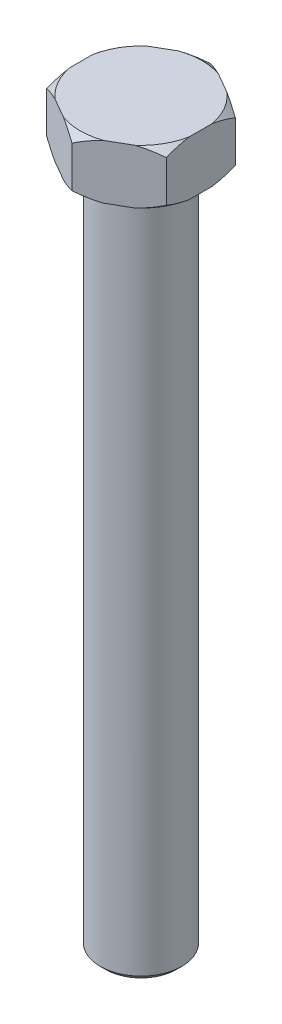
from build123d import *

# Parameters (mm, degrees)
BOSS_EXTRUDE1_DEPTH = 10
SKETCH2_R           = 7.5
BOSS_EXTRUDE2_DEPTH = 126
CHAMFER1_SIZE       = 1
SCALE1_SCALE        = 0.18
SCALE2_SCALE        = 1.04


with BuildPart() as part:
    # Sketch1 → Boss-Extrude1 (new body)
    with BuildSketch(Plane(origin=(0, 0, 0), x_dir=(1, 0, 0), z_dir=(0, 1, 0))):
        Polygon((0, 12.701705922), (-11, 6.350852961), (-11, -6.350852961), (0, -12.701705922), (11, -6.350852961), (11, 6.350852961), align=None)
    extrude(amount=BOSS_EXTRUDE1_DEPTH)

    # Sketch2 → Boss-Extrude2 (add)
    with BuildSketch(Plane.XZ):
        Circle(SKETCH2_R)
    extrude(amount=BOSS_EXTRUDE2_DEPTH)

    # Chamfer1
    chamfer1_edges = [part.edges().sort_by_distance(p)[0] for p in [
        (-7.5, -126, 0),
    ]]
    chamfer(chamfer1_edges, length=CHAMFER1_SIZE)

    # Sketch4 → Cut-Revolve2 (revolve, cut)
    with BuildSketch(Plane(origin=(0, 0, 0), x_dir=(0, 0, -1), z_dir=(1, 0, 0))):
        Polygon((-12.701705922, 10), (-12.701705922, 8.8), (-11.201705922, 10), align=None)
        Polygon((-12.701705922, 0), (-12.701705922, 1.2), (-11.201705922, 0), align=None)
    revolve(axis=Axis((0, 0, 0), (0, 1, 0)), mode=Mode.SUBTRACT)


with BuildPart() as part_1:
    # Scale1: scaled about (0, -52.210522466, 0)
    add(part.part.scale(SCALE1_SCALE).moved(Location((0, -42.812628422, 0))))


with BuildPart() as part_2:
    # Scale2: scaled about (0, -52.210522466, 0)
    add(part_1.part.scale(SCALE2_SCALE).moved(Location((0, 2.088420899, 0))))


solid = part_2.part
